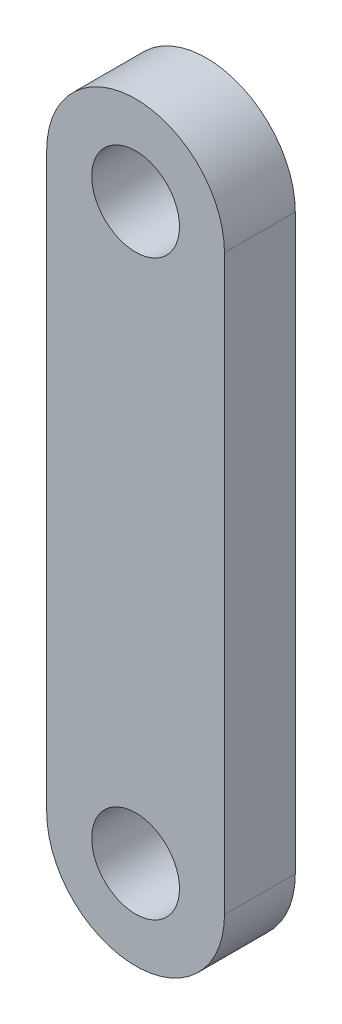
from build123d import *

# Parameters (mm, degrees)
SKETCH1_R           = 3.937
BOSS_EXTRUDE1_DEPTH = 6.35


with BuildPart() as part:
    # Sketch1 → Boss-Extrude1 (new body)
    with BuildSketch(Plane.XY):
        with BuildLine():
            Line((7.9756, 38.075002032), (7.9756, -13.359997968))
            ThreePointArc((7.9756, -13.359997968), (0, -21.335597968), (-7.9756, -13.359997968))
            Line((-7.9756, -13.359997968), (-7.9756, 38.075002032))
            ThreePointArc((-7.9756, 38.075002032), (0, 46.050602032), (7.9756, 38.075002032))
        make_face()
        with Locations((0, 38.075002032)):
            Circle(SKETCH1_R, mode=Mode.SUBTRACT)
        with Locations((0, -13.359997968)):
            Circle(SKETCH1_R, mode=Mode.SUBTRACT)
    extrude(amount=BOSS_EXTRUDE1_DEPTH)


solid = part.part
